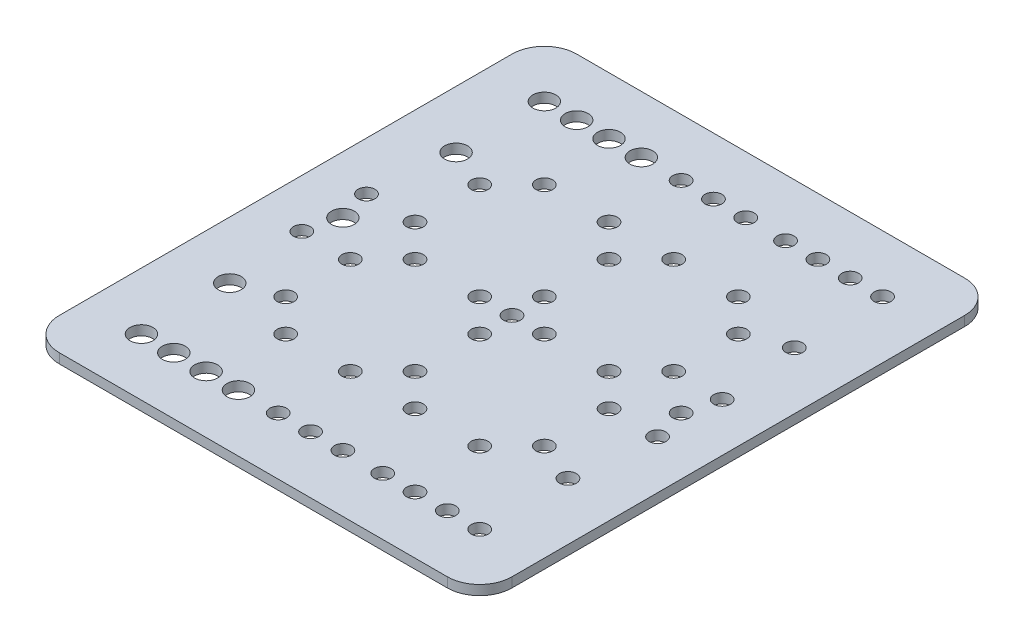
from build123d import *

# Parameters (mm, degrees)
SKETCH1_R           = 3.55
SKETCH1_R_2         = 2.6
BOSS_EXTRUDE1_DEPTH = 3


with BuildPart() as part:
    # Sketch1 → Boss-Extrude1 (new body)
    with BuildSketch(Plane(origin=(0, 0, 0), x_dir=(1, 0, 0), z_dir=(0, 1, 0))):
        with BuildLine():
            Line((60, -80), (-60, -80))
            ThreePointArc((-60, -80), (-67.071067812, -77.071067812), (-70, -70))
            Line((-70, -70), (-70, 70))
            ThreePointArc((-70, 70), (-67.071067812, 77.071067812), (-60, 80))
            Line((-60, 80), (60, 80))
            ThreePointArc((60, 80), (67.071067812, 77.071067812), (70, 70))
            Line((70, 70), (70, -70))
            ThreePointArc((70, -70), (67.071067812, -77.071067812), (60, -80))
        make_face()
        with Locations((-42.3, 62.3)):
            Circle(SKETCH1_R, mode=Mode.SUBTRACT)
        with Locations((0, 10)):
            Circle(SKETCH1_R_2, mode=Mode.SUBTRACT)
        Circle(SKETCH1_R_2, mode=Mode.SUBTRACT)
        with Locations((10, 0)):
            Circle(SKETCH1_R_2, mode=Mode.SUBTRACT)
        with Locations((-10, 0)):
            Circle(SKETCH1_R_2, mode=Mode.SUBTRACT)
        with Locations((-52.3, 62.3)):
            Circle(SKETCH1_R, mode=Mode.SUBTRACT)
        with Locations((-52.3, 0)):
            Circle(SKETCH1_R, mode=Mode.SUBTRACT)
        with Locations((-52.3, -62.3)):
            Circle(SKETCH1_R, mode=Mode.SUBTRACT)
        with Locations((-40, 30)):
            Circle(SKETCH1_R_2, mode=Mode.SUBTRACT)
        with Locations((-40, 10)):
            Circle(SKETCH1_R_2, mode=Mode.SUBTRACT)
        with Locations((-30, 40)):
            Circle(SKETCH1_R_2, mode=Mode.SUBTRACT)
        with Locations((0, 30)):
            Circle(SKETCH1_R_2, mode=Mode.SUBTRACT)
        with Locations((-10, 62.3)):
            Circle(SKETCH1_R_2, mode=Mode.SUBTRACT)
        with Locations((0, 62.3)):
            Circle(SKETCH1_R_2, mode=Mode.SUBTRACT)
        with Locations((10, 62.3)):
            Circle(SKETCH1_R_2, mode=Mode.SUBTRACT)
        with Locations((-10, 40)):
            Circle(SKETCH1_R_2, mode=Mode.SUBTRACT)
        with Locations((30, 40)):
            Circle(SKETCH1_R_2, mode=Mode.SUBTRACT)
        with Locations((40, 30)):
            Circle(SKETCH1_R_2, mode=Mode.SUBTRACT)
        with Locations((40, 10)):
            Circle(SKETCH1_R_2, mode=Mode.SUBTRACT)
        with Locations((42.3, 62.3)):
            Circle(SKETCH1_R_2, mode=Mode.SUBTRACT)
        with Locations((52.3, 62.3)):
            Circle(SKETCH1_R_2, mode=Mode.SUBTRACT)
        with Locations((52.3, 0)):
            Circle(SKETCH1_R_2, mode=Mode.SUBTRACT)
        with Locations((40, -10)):
            Circle(SKETCH1_R_2, mode=Mode.SUBTRACT)
        with Locations((52.3, -62.3)):
            Circle(SKETCH1_R_2, mode=Mode.SUBTRACT)
        with Locations((42.3, -62.3)):
            Circle(SKETCH1_R_2, mode=Mode.SUBTRACT)
        with Locations((40, -30)):
            Circle(SKETCH1_R_2, mode=Mode.SUBTRACT)
        with Locations((0, -10)):
            Circle(SKETCH1_R_2, mode=Mode.SUBTRACT)
        with Locations((30, -40)):
            Circle(SKETCH1_R_2, mode=Mode.SUBTRACT)
        with Locations((10, 40)):
            Circle(SKETCH1_R_2, mode=Mode.SUBTRACT)
        with Locations((10, -62.3)):
            Circle(SKETCH1_R_2, mode=Mode.SUBTRACT)
        with Locations((0, -62.3)):
            Circle(SKETCH1_R_2, mode=Mode.SUBTRACT)
        with Locations((-10, -62.3)):
            Circle(SKETCH1_R_2, mode=Mode.SUBTRACT)
        with Locations((30, 0)):
            Circle(SKETCH1_R_2, mode=Mode.SUBTRACT)
        with Locations((-30, -40)):
            Circle(SKETCH1_R_2, mode=Mode.SUBTRACT)
        with Locations((-40, -30)):
            Circle(SKETCH1_R_2, mode=Mode.SUBTRACT)
        with Locations((-40, -10)):
            Circle(SKETCH1_R_2, mode=Mode.SUBTRACT)
        with Locations((-42.3, -62.3)):
            Circle(SKETCH1_R, mode=Mode.SUBTRACT)
        with Locations((-32.3, 62.3)):
            Circle(SKETCH1_R, mode=Mode.SUBTRACT)
        with Locations((32.3, 62.3)):
            Circle(SKETCH1_R_2, mode=Mode.SUBTRACT)
        with Locations((22.3, -62.3)):
            Circle(SKETCH1_R_2, mode=Mode.SUBTRACT)
        with Locations((-30, 0)):
            Circle(SKETCH1_R_2, mode=Mode.SUBTRACT)
        with Locations((-52.3, 35)):
            Circle(SKETCH1_R, mode=Mode.SUBTRACT)
        with Locations((32.3, -62.3)):
            Circle(SKETCH1_R_2, mode=Mode.SUBTRACT)
        with Locations((-32.3, -62.3)):
            Circle(SKETCH1_R, mode=Mode.SUBTRACT)
        with Locations((-52.3, -35)):
            Circle(SKETCH1_R, mode=Mode.SUBTRACT)
        with Locations((52.3, 35)):
            Circle(SKETCH1_R_2, mode=Mode.SUBTRACT)
        with Locations((52.3, -35)):
            Circle(SKETCH1_R_2, mode=Mode.SUBTRACT)
        with Locations((-22.3, 62.3)):
            Circle(SKETCH1_R, mode=Mode.SUBTRACT)
        with Locations((22.3, 62.3)):
            Circle(SKETCH1_R_2, mode=Mode.SUBTRACT)
        with Locations((-22.3, -62.3)):
            Circle(SKETCH1_R, mode=Mode.SUBTRACT)
        with Locations((10, -40)):
            Circle(SKETCH1_R_2, mode=Mode.SUBTRACT)
        with Locations((-10, -40)):
            Circle(SKETCH1_R_2, mode=Mode.SUBTRACT)
        with Locations((0, -30)):
            Circle(SKETCH1_R_2, mode=Mode.SUBTRACT)
        with Locations((-55, 10)):
            Circle(SKETCH1_R_2, mode=Mode.SUBTRACT)
        with Locations((55, 10)):
            Circle(SKETCH1_R_2, mode=Mode.SUBTRACT)
        with Locations((55, -10)):
            Circle(SKETCH1_R_2, mode=Mode.SUBTRACT)
        with Locations((-55, -10)):
            Circle(SKETCH1_R_2, mode=Mode.SUBTRACT)
    extrude(amount=BOSS_EXTRUDE1_DEPTH)


solid = part.part
